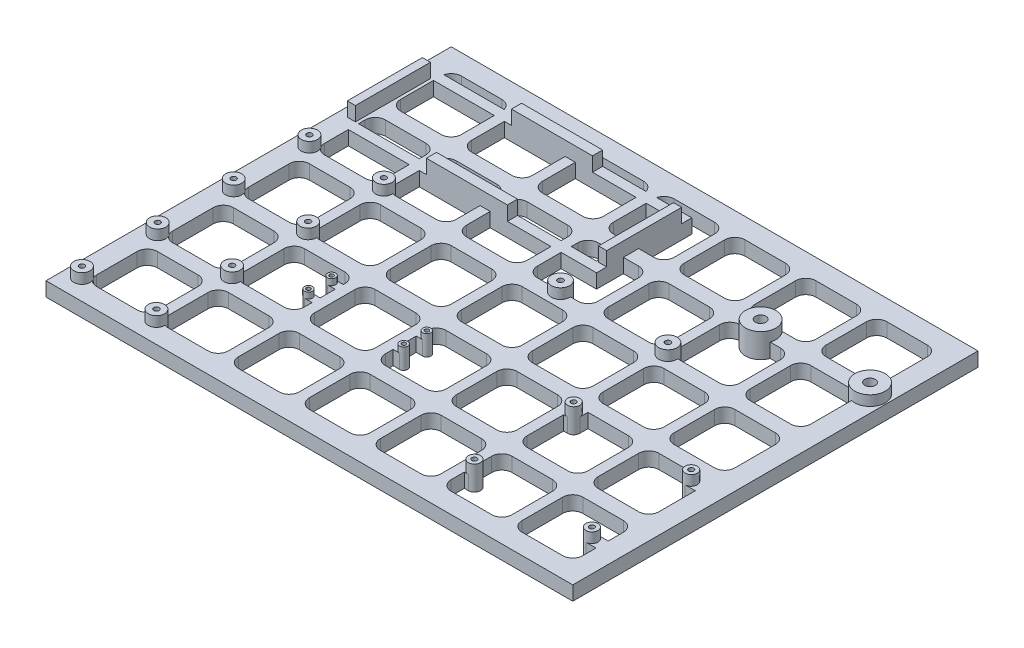
from build123d import *

# Parameters (mm, degrees)
SKETCH1_W                  = 260
SKETCH1_H                  = 200
BOSS_EXTRUDE1_DEPTH        = 7
CUT_EXTRUDE4_DEPTH         = 10
SKETCH10_R                 = 7.5
BOSS_EXTRUDE3_DEPTH        = 5
BOSS_EXTRUDE3_DEPTH_BACK   = 7
SKETCH11_R                 = 2.6
CUT_EXTRUDE2_DEPTH         = 13
SKETCH16_R                 = 4
BOSS_EXTRUDE6_DEPTH        = 5
BOSS_EXTRUDE6_DEPTH_BACK   = 7
SKETCH17_R                 = 1.3
CUT_EXTRUDE5_DEPTH         = 13
SKETCH18_R                 = 4.5
BOSS_EXTRUDE7_DEPTH        = 5
BOSS_EXTRUDE7_DEPTH_BACK   = 7
SKETCH19_R                 = 1.35
CUT_EXTRUDE6_DEPTH         = 13
SKETCH9_R                  = 6
BOSS_EXTRUDE2_DEPTH        = 5
BOSS_EXTRUDE2_DEPTH_BACK   = 7
SKETCH8_R                  = 1.25
CUT_EXTRUDE1_DEPTH         = 6
CUT_EXTRUDE1_DEPTH_BACK    = 8
SKETCH28_R                 = 7
SKETCH28_R_2               = 3
CUT_EXTRUDE8_DEPTH         = 5
SKETCH20_W                 = 4
SKETCH20_H                 = 37
SKETCH20_W_2               = 40
SKETCH20_H_2               = 5
BOSS_EXTRUDE8_DEPTH        = 7
SKETCH26_W                 = 128
SKETCH26_H                 = 47
SKETCH26_W_2               = 118
SKETCH26_H_2               = 37
BOSS_EXTRUDE12_DEPTH       = 7
SKETCH23_R                 = 2
BOSS_EXTRUDE9_DEPTH        = 3
BOSS_EXTRUDE9_DEPTH_BACK   = 7
BOSS_EXTRUDE9_2_DEPTH      = 3
BOSS_EXTRUDE9_2_DEPTH_BACK = 7
BOSS_EXTRUDE9_3_DEPTH      = 3
BOSS_EXTRUDE9_3_DEPTH_BACK = 7
BOSS_EXTRUDE9_4_DEPTH      = 3
BOSS_EXTRUDE9_4_DEPTH_BACK = 7
CUT_EXTRUDE10_DEPTH        = 8
BOSS_EXTRUDE13_DEPTH       = 7
SKETCH24_R                 = 1
CUT_EXTRUDE12_DEPTH        = 5
CUT_EXTRUDE12_DEPTH_BACK   = 11


with BuildPart() as part:
    # Sketch1 → Boss-Extrude1 (new body)
    with BuildSketch(Plane(origin=(0, 0, 0), x_dir=(1, 0, 0), z_dir=(0, 1, 0))):
        Rectangle(SKETCH1_W, SKETCH1_H)
    extrude(amount=BOSS_EXTRUDE1_DEPTH)

    # Sketch15 → Cut-Extrude4 (cut)
    with BuildSketch(Plane(origin=(0, 7, 0), x_dir=(1, 0, 0), z_dir=(0, 1, 0))):
        with BuildLine():
            Line((-115, 90), (-95, 90))
            ThreePointArc((-95, 90), (-91.464466094, 88.535533906), (-90, 85))
            Line((-90, 85), (-90, 65))
            ThreePointArc((-90, 65), (-91.464466094, 61.464466094), (-95, 60))
            Line((-95, 60), (-115, 60))
            ThreePointArc((-115, 60), (-118.535533906, 61.464466094), (-120, 65))
            Line((-120, 65), (-120, 85))
            ThreePointArc((-120, 85), (-118.535533906, 88.535533906), (-115, 90))
        make_face()
        with BuildLine():
            Line((-85, 85), (-85, 65))
            ThreePointArc((-85, 65), (-83.535533906, 61.464466094), (-80, 60))
            Line((-80, 60), (-60, 60))
            ThreePointArc((-60, 60), (-56.464466094, 61.464466094), (-55, 65))
            Line((-55, 65), (-55, 85))
            ThreePointArc((-55, 85), (-56.464466094, 88.535533906), (-60, 90))
            Line((-60, 90), (-80, 90))
            ThreePointArc((-80, 90), (-83.535533906, 88.535533906), (-85, 85))
        make_face()
        with BuildLine():
            Line((-50, 85), (-50, 65))
            ThreePointArc((-50, 65), (-48.535533906, 61.464466094), (-45, 60))
            Line((-45, 60), (-25, 60))
            ThreePointArc((-25, 60), (-21.464466094, 61.464466094), (-20, 65))
            Line((-20, 65), (-20, 85))
            ThreePointArc((-20, 85), (-21.464466094, 88.535533906), (-25, 90))
            Line((-25, 90), (-45, 90))
            ThreePointArc((-45, 90), (-48.535533906, 88.535533906), (-50, 85))
        make_face()
        with BuildLine():
            Line((-15, 85), (-15, 65))
            ThreePointArc((-15, 65), (-13.535533906, 61.464466094), (-10, 60))
            Line((-10, 60), (10, 60))
            ThreePointArc((10, 60), (13.535533906, 61.464466094), (15, 65))
            Line((15, 65), (15, 85))
            ThreePointArc((15, 85), (13.535533906, 88.535533906), (10, 90))
            Line((10, 90), (-10, 90))
            ThreePointArc((-10, 90), (-13.535533906, 88.535533906), (-15, 85))
        make_face()
        with BuildLine():
            Line((20, 85), (20, 65))
            ThreePointArc((20, 65), (21.464466094, 61.464466094), (25, 60))
            Line((25, 60), (45, 60))
            ThreePointArc((45, 60), (48.535533906, 61.464466094), (50, 65))
            Line((50, 65), (50, 85))
            ThreePointArc((50, 85), (48.535533906, 88.535533906), (45, 90))
            Line((45, 90), (25, 90))
            ThreePointArc((25, 90), (21.464466094, 88.535533906), (20, 85))
        make_face()
        with BuildLine():
            Line((55, 85), (55, 65))
            ThreePointArc((55, 65), (56.464466094, 61.464466094), (60, 60))
            Line((60, 60), (80, 60))
            ThreePointArc((80, 60), (83.535533906, 61.464466094), (85, 65))
            Line((85, 65), (85, 85))
            ThreePointArc((85, 85), (83.535533906, 88.535533906), (80, 90))
            Line((80, 90), (60, 90))
            ThreePointArc((60, 90), (56.464466094, 88.535533906), (55, 85))
        make_face()
        with BuildLine():
            Line((90, 85), (90, 65))
            ThreePointArc((90, 65), (91.464466094, 61.464466094), (95, 60))
            Line((95, 60), (115, 60))
            ThreePointArc((115, 60), (118.535533906, 61.464466094), (120, 65))
            Line((120, 65), (120, 85))
            ThreePointArc((120, 85), (118.535533906, 88.535533906), (115, 90))
            Line((115, 90), (95, 90))
            ThreePointArc((95, 90), (91.464466094, 88.535533906), (90, 85))
        make_face()
        with BuildLine():
            Line((-85, 47.5), (-85, 27.5))
            ThreePointArc((-85, 27.5), (-83.535533906, 23.964466094), (-80, 22.5))
            Line((-80, 22.5), (-60, 22.5))
            ThreePointArc((-60, 22.5), (-56.464466094, 23.964466094), (-55, 27.5))
            Line((-55, 27.5), (-55, 47.5))
            ThreePointArc((-55, 47.5), (-56.464466094, 51.035533906), (-60, 52.5))
            Line((-60, 52.5), (-80, 52.5))
            ThreePointArc((-80, 52.5), (-83.535533906, 51.035533906), (-85, 47.5))
        make_face()
        with BuildLine():
            Line((-50, 47.5), (-50, 27.5))
            ThreePointArc((-50, 27.5), (-48.535533906, 23.964466094), (-45, 22.5))
            Line((-45, 22.5), (-25, 22.5))
            ThreePointArc((-25, 22.5), (-21.464466094, 23.964466094), (-20, 27.5))
            Line((-20, 27.5), (-20, 47.5))
            ThreePointArc((-20, 47.5), (-21.464466094, 51.035533906), (-25, 52.5))
            Line((-25, 52.5), (-45, 52.5))
            ThreePointArc((-45, 52.5), (-48.535533906, 51.035533906), (-50, 47.5))
        make_face()
        with BuildLine():
            Line((-15, 47.5), (-15, 27.5))
            ThreePointArc((-15, 27.5), (-13.535533906, 23.964466094), (-10, 22.5))
            Line((-10, 22.5), (10, 22.5))
            ThreePointArc((10, 22.5), (13.535533906, 23.964466094), (15, 27.5))
            Line((15, 27.5), (15, 47.5))
            ThreePointArc((15, 47.5), (13.535533906, 51.035533906), (10, 52.5))
            Line((10, 52.5), (-10, 52.5))
            ThreePointArc((-10, 52.5), (-13.535533906, 51.035533906), (-15, 47.5))
        make_face()
        with BuildLine():
            Line((20, 47.5), (20, 27.5))
            ThreePointArc((20, 27.5), (21.464466094, 23.964466094), (25, 22.5))
            Line((25, 22.5), (45, 22.5))
            ThreePointArc((45, 22.5), (48.535533906, 23.964466094), (50, 27.5))
            Line((50, 27.5), (50, 47.5))
            ThreePointArc((50, 47.5), (48.535533906, 51.035533906), (45, 52.5))
            Line((45, 52.5), (25, 52.5))
            ThreePointArc((25, 52.5), (21.464466094, 51.035533906), (20, 47.5))
        make_face()
        with BuildLine():
            Line((55, 47.5), (55, 27.5))
            ThreePointArc((55, 27.5), (56.464466094, 23.964466094), (60, 22.5))
            Line((60, 22.5), (80, 22.5))
            ThreePointArc((80, 22.5), (83.535533906, 23.964466094), (85, 27.5))
            Line((85, 27.5), (85, 47.5))
            ThreePointArc((85, 47.5), (83.535533906, 51.035533906), (80, 52.5))
            Line((80, 52.5), (60, 52.5))
            ThreePointArc((60, 52.5), (56.464466094, 51.035533906), (55, 47.5))
        make_face()
        with BuildLine():
            Line((90, 47.5), (90, 27.5))
            ThreePointArc((90, 27.5), (91.464466094, 23.964466094), (95, 22.5))
            Line((95, 22.5), (115, 22.5))
            ThreePointArc((115, 22.5), (118.535533906, 23.964466094), (120, 27.5))
            Line((120, 27.5), (120, 47.5))
            ThreePointArc((120, 47.5), (118.535533906, 51.035533906), (115, 52.5))
            Line((115, 52.5), (95, 52.5))
            ThreePointArc((95, 52.5), (91.464466094, 51.035533906), (90, 47.5))
        make_face()
        with BuildLine():
            Line((-85, 10), (-85, -10))
            ThreePointArc((-85, -10), (-83.535533906, -13.535533906), (-80, -15))
            Line((-80, -15), (-60, -15))
            ThreePointArc((-60, -15), (-56.464466094, -13.535533906), (-55, -10))
            Line((-55, -10), (-55, 10))
            ThreePointArc((-55, 10), (-56.464466094, 13.535533906), (-60, 15))
            Line((-60, 15), (-80, 15))
            ThreePointArc((-80, 15), (-83.535533906, 13.535533906), (-85, 10))
        make_face()
        with BuildLine():
            Line((-50, 10), (-50, -10))
            ThreePointArc((-50, -10), (-48.535533906, -13.535533906), (-45, -15))
            Line((-45, -15), (-25, -15))
            ThreePointArc((-25, -15), (-21.464466094, -13.535533906), (-20, -10))
            Line((-20, -10), (-20, 10))
            ThreePointArc((-20, 10), (-21.464466094, 13.535533906), (-25, 15))
            Line((-25, 15), (-45, 15))
            ThreePointArc((-45, 15), (-48.535533906, 13.535533906), (-50, 10))
        make_face()
        with BuildLine():
            Line((-15, 10), (-15, -10))
            ThreePointArc((-15, -10), (-13.535533906, -13.535533906), (-10, -15))
            Line((-10, -15), (10, -15))
            ThreePointArc((10, -15), (13.535533906, -13.535533906), (15, -10))
            Line((15, -10), (15, 10))
            ThreePointArc((15, 10), (13.535533906, 13.535533906), (10, 15))
            Line((10, 15), (-10, 15))
            ThreePointArc((-10, 15), (-13.535533906, 13.535533906), (-15, 10))
        make_face()
        with BuildLine():
            Line((20, 10), (20, -10))
            ThreePointArc((20, -10), (21.464466094, -13.535533906), (25, -15))
            Line((25, -15), (45, -15))
            ThreePointArc((45, -15), (48.535533906, -13.535533906), (50, -10))
            Line((50, -10), (50, 10))
            ThreePointArc((50, 10), (48.535533906, 13.535533906), (45, 15))
            Line((45, 15), (25, 15))
            ThreePointArc((25, 15), (21.464466094, 13.535533906), (20, 10))
        make_face()
        with BuildLine():
            Line((55, 10), (55, -10))
            ThreePointArc((55, -10), (56.464466094, -13.535533906), (60, -15))
            Line((60, -15), (80, -15))
            ThreePointArc((80, -15), (83.535533906, -13.535533906), (85, -10))
            Line((85, -10), (85, 10))
            ThreePointArc((85, 10), (83.535533906, 13.535533906), (80, 15))
            Line((80, 15), (60, 15))
            ThreePointArc((60, 15), (56.464466094, 13.535533906), (55, 10))
        make_face()
        with BuildLine():
            Line((90, 10), (90, -10))
            ThreePointArc((90, -10), (91.464466094, -13.535533906), (95, -15))
            Line((95, -15), (115, -15))
            ThreePointArc((115, -15), (118.535533906, -13.535533906), (120, -10))
            Line((120, -10), (120, 10))
            ThreePointArc((120, 10), (118.535533906, 13.535533906), (115, 15))
            Line((115, 15), (95, 15))
            ThreePointArc((95, 15), (91.464466094, 13.535533906), (90, 10))
        make_face()
        with BuildLine():
            Line((-85, -27.5), (-85, -47.5))
            ThreePointArc((-85, -47.5), (-83.535533906, -51.035533906), (-80, -52.5))
            Line((-80, -52.5), (-60, -52.5))
            ThreePointArc((-60, -52.5), (-56.464466094, -51.035533906), (-55, -47.5))
            Line((-55, -47.5), (-55, -27.5))
            ThreePointArc((-55, -27.5), (-56.464466094, -23.964466094), (-60, -22.5))
            Line((-60, -22.5), (-80, -22.5))
            ThreePointArc((-80, -22.5), (-83.535533906, -23.964466094), (-85, -27.5))
        make_face()
        with BuildLine():
            Line((-50, -27.5), (-50, -47.5))
            ThreePointArc((-50, -47.5), (-48.535533906, -51.035533906), (-45, -52.5))
            Line((-45, -52.5), (-25, -52.5))
            ThreePointArc((-25, -52.5), (-21.464466094, -51.035533906), (-20, -47.5))
            Line((-20, -47.5), (-20, -27.5))
            ThreePointArc((-20, -27.5), (-21.464466094, -23.964466094), (-25, -22.5))
            Line((-25, -22.5), (-45, -22.5))
            ThreePointArc((-45, -22.5), (-48.535533906, -23.964466094), (-50, -27.5))
        make_face()
        with BuildLine():
            Line((-15, -27.5), (-15, -47.5))
            ThreePointArc((-15, -47.5), (-13.535533906, -51.035533906), (-10, -52.5))
            Line((-10, -52.5), (10, -52.5))
            ThreePointArc((10, -52.5), (13.535533906, -51.035533906), (15, -47.5))
            Line((15, -47.5), (15, -27.5))
            ThreePointArc((15, -27.5), (13.535533906, -23.964466094), (10, -22.5))
            Line((10, -22.5), (-10, -22.5))
            ThreePointArc((-10, -22.5), (-13.535533906, -23.964466094), (-15, -27.5))
        make_face()
        with BuildLine():
            Line((20, -27.5), (20, -47.5))
            ThreePointArc((20, -47.5), (21.464466094, -51.035533906), (25, -52.5))
            Line((25, -52.5), (45, -52.5))
            ThreePointArc((45, -52.5), (48.535533906, -51.035533906), (50, -47.5))
            Line((50, -47.5), (50, -27.5))
            ThreePointArc((50, -27.5), (48.535533906, -23.964466094), (45, -22.5))
            Line((45, -22.5), (25, -22.5))
            ThreePointArc((25, -22.5), (21.464466094, -23.964466094), (20, -27.5))
        make_face()
        with BuildLine():
            Line((55, -27.5), (55, -47.5))
            ThreePointArc((55, -47.5), (56.464466094, -51.035533906), (60, -52.5))
            Line((60, -52.5), (80, -52.5))
            ThreePointArc((80, -52.5), (83.535533906, -51.035533906), (85, -47.5))
            Line((85, -47.5), (85, -27.5))
            ThreePointArc((85, -27.5), (83.535533906, -23.964466094), (80, -22.5))
            Line((80, -22.5), (60, -22.5))
            ThreePointArc((60, -22.5), (56.464466094, -23.964466094), (55, -27.5))
        make_face()
        with BuildLine():
            Line((90, -27.5), (90, -47.5))
            ThreePointArc((90, -47.5), (91.464466094, -51.035533906), (95, -52.5))
            Line((95, -52.5), (115, -52.5))
            ThreePointArc((115, -52.5), (118.535533906, -51.035533906), (120, -47.5))
            Line((120, -47.5), (120, -27.5))
            ThreePointArc((120, -27.5), (118.535533906, -23.964466094), (115, -22.5))
            Line((115, -22.5), (95, -22.5))
            ThreePointArc((95, -22.5), (91.464466094, -23.964466094), (90, -27.5))
        make_face()
        with BuildLine():
            Line((-85, -65), (-85, -85))
            ThreePointArc((-85, -85), (-83.535533906, -88.535533906), (-80, -90))
            Line((-80, -90), (-60, -90))
            ThreePointArc((-60, -90), (-56.464466094, -88.535533906), (-55, -85))
            Line((-55, -85), (-55, -65))
            ThreePointArc((-55, -65), (-56.464466094, -61.464466094), (-60, -60))
            Line((-60, -60), (-80, -60))
            ThreePointArc((-80, -60), (-83.535533906, -61.464466094), (-85, -65))
        make_face()
        with BuildLine():
            Line((-50, -65), (-50, -85))
            ThreePointArc((-50, -85), (-48.535533906, -88.535533906), (-45, -90))
            Line((-45, -90), (-25, -90))
            ThreePointArc((-25, -90), (-21.464466094, -88.535533906), (-20, -85))
            Line((-20, -85), (-20, -65))
            ThreePointArc((-20, -65), (-21.464466094, -61.464466094), (-25, -60))
            Line((-25, -60), (-45, -60))
            ThreePointArc((-45, -60), (-48.535533906, -61.464466094), (-50, -65))
        make_face()
        with BuildLine():
            Line((-15, -65), (-15, -85))
            ThreePointArc((-15, -85), (-13.535533906, -88.535533906), (-10, -90))
            Line((-10, -90), (10, -90))
            ThreePointArc((10, -90), (13.535533906, -88.535533906), (15, -85))
            Line((15, -85), (15, -65))
            ThreePointArc((15, -65), (13.535533906, -61.464466094), (10, -60))
            Line((10, -60), (-10, -60))
            ThreePointArc((-10, -60), (-13.535533906, -61.464466094), (-15, -65))
        make_face()
        with BuildLine():
            Line((20, -65), (20, -85))
            ThreePointArc((20, -85), (21.464466094, -88.535533906), (25, -90))
            Line((25, -90), (45, -90))
            ThreePointArc((45, -90), (48.535533906, -88.535533906), (50, -85))
            Line((50, -85), (50, -65))
            ThreePointArc((50, -65), (48.535533906, -61.464466094), (45, -60))
            Line((45, -60), (25, -60))
            ThreePointArc((25, -60), (21.464466094, -61.464466094), (20, -65))
        make_face()
        with BuildLine():
            Line((55, -65), (55, -85))
            ThreePointArc((55, -85), (56.464466094, -88.535533906), (60, -90))
            Line((60, -90), (80, -90))
            ThreePointArc((80, -90), (83.535533906, -88.535533906), (85, -85))
            Line((85, -85), (85, -65))
            ThreePointArc((85, -65), (83.535533906, -61.464466094), (80, -60))
            Line((80, -60), (60, -60))
            ThreePointArc((60, -60), (56.464466094, -61.464466094), (55, -65))
        make_face()
        with BuildLine():
            Line((90, -65), (90, -85))
            ThreePointArc((90, -85), (91.464466094, -88.535533906), (95, -90))
            Line((95, -90), (115, -90))
            ThreePointArc((115, -90), (118.535533906, -88.535533906), (120, -85))
            Line((120, -85), (120, -65))
            ThreePointArc((120, -65), (118.535533906, -61.464466094), (115, -60))
            Line((115, -60), (95, -60))
            ThreePointArc((95, -60), (91.464466094, -61.464466094), (90, -65))
        make_face()
        with BuildLine():
            Line((-120, 47.5), (-120, 27.5))
            ThreePointArc((-120, 27.5), (-118.535533906, 23.964466094), (-115, 22.5))
            Line((-115, 22.5), (-95, 22.5))
            ThreePointArc((-95, 22.5), (-91.464466094, 23.964466094), (-90, 27.5))
            Line((-90, 27.5), (-90, 47.5))
            ThreePointArc((-90, 47.5), (-91.464466094, 51.035533906), (-95, 52.5))
            Line((-95, 52.5), (-115, 52.5))
            ThreePointArc((-115, 52.5), (-118.535533906, 51.035533906), (-120, 47.5))
        make_face()
        with BuildLine():
            Line((-120, 10), (-120, -10))
            ThreePointArc((-120, -10), (-118.535533906, -13.535533906), (-115, -15))
            Line((-115, -15), (-95, -15))
            ThreePointArc((-95, -15), (-91.464466094, -13.535533906), (-90, -10))
            Line((-90, -10), (-90, 10))
            ThreePointArc((-90, 10), (-91.464466094, 13.535533906), (-95, 15))
            Line((-95, 15), (-115, 15))
            ThreePointArc((-115, 15), (-118.535533906, 13.535533906), (-120, 10))
        make_face()
        with BuildLine():
            Line((-120, -27.5), (-120, -47.5))
            ThreePointArc((-120, -47.5), (-118.535533906, -51.035533906), (-115, -52.5))
            Line((-115, -52.5), (-95, -52.5))
            ThreePointArc((-95, -52.5), (-91.464466094, -51.035533906), (-90, -47.5))
            Line((-90, -47.5), (-90, -27.5))
            ThreePointArc((-90, -27.5), (-91.464466094, -23.964466094), (-95, -22.5))
            Line((-95, -22.5), (-115, -22.5))
            ThreePointArc((-115, -22.5), (-118.535533906, -23.964466094), (-120, -27.5))
        make_face()
        with BuildLine():
            Line((-120, -65), (-120, -85))
            ThreePointArc((-120, -85), (-118.535533906, -88.535533906), (-115, -90))
            Line((-115, -90), (-95, -90))
            ThreePointArc((-95, -90), (-91.464466094, -88.535533906), (-90, -85))
            Line((-90, -85), (-90, -65))
            ThreePointArc((-90, -65), (-91.464466094, -61.464466094), (-95, -60))
            Line((-95, -60), (-115, -60))
            ThreePointArc((-115, -60), (-118.535533906, -61.464466094), (-120, -65))
        make_face()
    extrude(amount=-CUT_EXTRUDE4_DEPTH, mode=Mode.SUBTRACT)

    # Sketch10 → Boss-Extrude3 (add, two sides)
    with BuildSketch(Plane(origin=(0, 7, 0), x_dir=(1, 0, 0), z_dir=(0, 1, 0))) as boss_extrude3_sk:
        with Locations((67.819740349, 54.898416851)):
            Circle(SKETCH10_R)
        with Locations((121.819740349, 54.898416851)):
            Circle(SKETCH10_R)
    extrude(amount=BOSS_EXTRUDE3_DEPTH)
    extrude(boss_extrude3_sk.sketch, amount=-BOSS_EXTRUDE3_DEPTH_BACK)

    # Sketch11 → Cut-Extrude2 (cut, through all)
    with BuildSketch(Plane(origin=(0, 12, 0), x_dir=(1, 0, 0), z_dir=(0, 1, 0))):
        with Locations((67.819740349, 54.898416851)):
            Circle(SKETCH11_R)
        with Locations((121.819740349, 54.898416851)):
            Circle(SKETCH11_R)
    extrude(amount=-CUT_EXTRUDE2_DEPTH, mode=Mode.SUBTRACT)

    # Sketch16 → Boss-Extrude6 (add, two sides)
    with BuildSketch(Plane(origin=(0, 7, 0), x_dir=(1, 0, 0), z_dir=(0, 1, 0))) as boss_extrude6_sk:
        with Locations((-122.3709, -89.881222269)):
            Circle(SKETCH16_R)
        with Locations((-85.6291, -89.881222269)):
            Circle(SKETCH16_R)
        with Locations((-85.6291, -52.501722269)):
            Circle(SKETCH16_R)
        with Locations((-122.3709, -52.501722269)):
            Circle(SKETCH16_R)
        with Locations((-122.3709, -14.984574719)):
            Circle(SKETCH16_R)
        with Locations((-85.6291, -14.984574719)):
            Circle(SKETCH16_R)
        with Locations((-85.6291, 22.394925281)):
            Circle(SKETCH16_R)
        with Locations((-122.3709, 22.394925281)):
            Circle(SKETCH16_R)
    extrude(amount=BOSS_EXTRUDE6_DEPTH)
    extrude(boss_extrude6_sk.sketch, amount=-BOSS_EXTRUDE6_DEPTH_BACK)

    # Sketch17 → Cut-Extrude5 (cut, through all)
    with BuildSketch(Plane(origin=(0, 12, 0), x_dir=(1, 0, 0), z_dir=(0, 1, 0))):
        with Locations((-122.3709, -52.501722269)):
            Circle(SKETCH17_R)
        with Locations((-85.6291, -52.501722269)):
            Circle(SKETCH17_R)
        with Locations((-85.6291, -89.881222269)):
            Circle(SKETCH17_R)
        with Locations((-122.3709, -89.881222269)):
            Circle(SKETCH17_R)
        with Locations((-122.3709, -14.984574719)):
            Circle(SKETCH17_R)
        with Locations((-122.3709, 22.394925281)):
            Circle(SKETCH17_R)
        with Locations((-85.6291, 22.394925281)):
            Circle(SKETCH17_R)
        with Locations((-85.6291, -14.984574719)):
            Circle(SKETCH17_R)
    extrude(amount=-CUT_EXTRUDE5_DEPTH, mode=Mode.SUBTRACT)

    # Sketch18 → Boss-Extrude7 (add, two sides)
    with BuildSketch(Plane(origin=(0, 7, 0), x_dir=(1, 0, 0), z_dir=(0, 1, 0))) as boss_extrude7_sk:
        with Locations((1.833333333, 22.121784759)):
            Circle(SKETCH18_R)
        with Locations((54.833333333, 22.121784759)):
            Circle(SKETCH18_R)
    extrude(amount=BOSS_EXTRUDE7_DEPTH)
    extrude(boss_extrude7_sk.sketch, amount=-BOSS_EXTRUDE7_DEPTH_BACK)

    # Sketch19 → Cut-Extrude6 (cut, through all)
    with BuildSketch(Plane(origin=(0, 12, 0), x_dir=(1, 0, 0), z_dir=(0, 1, 0))):
        with Locations((1.833333333, 22.121784759)):
            Circle(SKETCH19_R)
        with Locations((54.833333333, 22.121784759)):
            Circle(SKETCH19_R)
    extrude(amount=-CUT_EXTRUDE6_DEPTH, mode=Mode.SUBTRACT)

    # Sketch9 → Boss-Extrude2 (add, two sides)
    with BuildSketch(Plane(origin=(0, 7, 0), x_dir=(1, 0, 0), z_dir=(0, 1, 0))) as boss_extrude2_sk:
        with Locations((56.97501713, -26.535533906)):
            Circle(SKETCH9_R)
        with Locations((114.97501713, -26.535533906)):
            Circle(SKETCH9_R)
        with Locations((114.97501713, -75.535533906)):
            Circle(SKETCH9_R)
        with Locations((56.97501713, -75.535533906)):
            Circle(SKETCH9_R)
    extrude(amount=BOSS_EXTRUDE2_DEPTH)
    extrude(boss_extrude2_sk.sketch, amount=-BOSS_EXTRUDE2_DEPTH_BACK)

    # Sketch8 → Cut-Extrude1 (cut, two sides)
    with BuildSketch(Plane(origin=(0, 7, 0), x_dir=(1, 0, 0), z_dir=(0, 1, 0))) as cut_extrude1_sk:
        with Locations((114.97501713, -75.535533906)):
            Circle(SKETCH8_R)
        with Locations((56.97501713, -75.535533906)):
            Circle(SKETCH8_R)
        with Locations((56.97501713, -26.535533906)):
            Circle(SKETCH8_R)
        with Locations((114.97501713, -26.535533906)):
            Circle(SKETCH8_R)
    extrude(amount=CUT_EXTRUDE1_DEPTH, mode=Mode.SUBTRACT)
    extrude(cut_extrude1_sk.sketch, amount=-CUT_EXTRUDE1_DEPTH_BACK, mode=Mode.SUBTRACT)

    # Sketch28 → Cut-Extrude8 (cut)
    with BuildSketch(Plane(origin=(0, 12, 0), x_dir=(1, 0, 0), z_dir=(0, 1, 0))):
        with Locations((56.97501713, -75.535533906)):
            Circle(SKETCH28_R)
        with Locations((56.97501713, -75.535533906)):
            Circle(SKETCH28_R_2, mode=Mode.SUBTRACT)
        with Locations((114.97501713, -75.535533906)):
            Circle(SKETCH28_R)
        with Locations((114.97501713, -75.535533906)):
            Circle(SKETCH28_R_2, mode=Mode.SUBTRACT)
        with Locations((56.97501713, -26.535533906)):
            Circle(SKETCH28_R)
        with Locations((56.97501713, -26.535533906)):
            Circle(SKETCH28_R_2, mode=Mode.SUBTRACT)
        with Locations((114.97501713, -26.535533906)):
            Circle(SKETCH28_R)
        with Locations((114.97501713, -26.535533906)):
            Circle(SKETCH28_R_2, mode=Mode.SUBTRACT)
    extrude(amount=-CUT_EXTRUDE8_DEPTH, mode=Mode.SUBTRACT)

    # Sketch20 → Boss-Extrude8 (add)
    with BuildSketch(Plane(origin=(0, 7, 0), x_dir=(1, 0, 0), z_dir=(0, 1, 0))):
        with Locations((-123.513851374, 62.741803697)):
            Rectangle(SKETCH20_W, SKETCH20_H)
        with Locations((0.486148626, 62.741803697)):
            Rectangle(SKETCH20_W, SKETCH20_H)
        with Locations((-61.513851374, 83.741803697)):
            Rectangle(SKETCH20_W_2, SKETCH20_H_2)
        with Locations((-61.513851374, 41.741803697)):
            Rectangle(SKETCH20_W_2, SKETCH20_H_2)
    extrude(amount=BOSS_EXTRUDE8_DEPTH)

    # Sketch26 → Boss-Extrude12 (add)
    with BuildSketch(Plane(origin=(0, 7, 0), x_dir=(1, 0, 0), z_dir=(0, 1, 0))):
        with Locations((-61.513851374, 62.741803697)):
            Rectangle(SKETCH26_W, SKETCH26_H)
        with Locations((-61.513851374, 62.741803697)):
            Rectangle(SKETCH26_W_2, SKETCH26_H_2, mode=Mode.SUBTRACT)
    extrude(amount=-BOSS_EXTRUDE12_DEPTH)

    # Sketch30 → Cut-Extrude10 (cut, through all)
    with BuildSketch(Plane(origin=(0, 7, 0), x_dir=(1, 0, 0), z_dir=(0, 1, 0))):
        with BuildLine():
            Line((55, -69.869908845), (55, -72.535533906))
            Line((55, -72.535533906), (56.97501713, -72.535533906))
            ThreePointArc((56.97501713, -72.535533906), (59.096337474, -73.414213562), (59.97501713, -75.535533906))
            ThreePointArc((59.97501713, -75.535533906), (59.096337474, -77.656854249), (56.97501713, -78.535533906))
            Line((56.97501713, -78.535533906), (55, -78.535533906))
            Line((55, -78.535533906), (55, -81.201158967))
            ThreePointArc((55, -81.201158967), (62.97501713, -75.535533906), (55, -69.869908845))
        make_face()
        with BuildLine():
            Line((120, -72.256883702), (120, -72.535533906))
            Line((120, -72.535533906), (114.97501713, -72.535533906))
            ThreePointArc((114.97501713, -72.535533906), (111.97501713, -75.535533906), (114.97501713, -78.535533906))
            Line((114.97501713, -78.535533906), (120, -78.535533906))
            Line((120, -78.535533906), (120, -78.81418411))
            ThreePointArc((120, -78.81418411), (108.97501713, -75.535533906), (120, -72.256883702))
        make_face()
        with BuildLine():
            Line((114.97501713, -29.535533906), (120, -29.535533906))
            Line((120, -29.535533906), (120, -29.81418411))
            ThreePointArc((120, -29.81418411), (111.306250987, -31.283181217), (110.534919598, -22.5))
            Line((110.534919598, -22.5), (111.97501713, -22.5))
            Line((111.97501713, -22.5), (111.97501713, -26.535533906))
            ThreePointArc((111.97501713, -26.535533906), (112.853696787, -28.656854249), (114.97501713, -29.535533906))
        make_face()
        with BuildLine():
            Line((56.97501713, -29.535533906), (55, -29.535533906))
            Line((55, -29.535533906), (55, -32.201158967))
            ThreePointArc((55, -32.201158967), (61.979742565, -29.845023795), (61.415114662, -22.5))
            Line((61.415114662, -22.5), (59.97501713, -22.5))
            Line((59.97501713, -22.5), (59.97501713, -26.535533906))
            ThreePointArc((59.97501713, -26.535533906), (59.096337474, -28.656854249), (56.97501713, -29.535533906))
        make_face()
    extrude(amount=-CUT_EXTRUDE10_DEPTH, mode=Mode.SUBTRACT)



with BuildPart() as body_2:
    # Sketch23 → Boss-Extrude9 (new body, two sides)
    with BuildSketch(Plane(origin=(0, 7, 0), x_dir=(1, 0, 0), z_dir=(0, 1, 0))) as boss_extrude9_sk:
        with Locations((-58.783450413, -30.269655173)):
            Circle(SKETCH23_R)
    extrude(amount=BOSS_EXTRUDE9_DEPTH)
    extrude(boss_extrude9_sk.sketch, amount=-BOSS_EXTRUDE9_DEPTH_BACK)


with BuildPart() as body_3:
    # Sketch23 → Boss-Extrude9 2 (new body, two sides)
    with BuildSketch(Plane(origin=(0, 7, 0), x_dir=(1, 0, 0), z_dir=(0, 1, 0))) as boss_extrude9_2_sk:
        with Locations((-58.783450413, -41.669655173)):
            Circle(SKETCH23_R)
    extrude(amount=BOSS_EXTRUDE9_2_DEPTH)
    extrude(boss_extrude9_2_sk.sketch, amount=-BOSS_EXTRUDE9_2_DEPTH_BACK)


with BuildPart() as body_4:
    # Sketch23 → Boss-Extrude9 3 (new body, two sides)
    with BuildSketch(Plane(origin=(0, 7, 0), x_dir=(1, 0, 0), z_dir=(0, 1, 0))) as boss_extrude9_3_sk:
        with Locations((-11.783450413, -41.669655173)):
            Circle(SKETCH23_R)
    extrude(amount=BOSS_EXTRUDE9_3_DEPTH)
    extrude(boss_extrude9_3_sk.sketch, amount=-BOSS_EXTRUDE9_3_DEPTH_BACK)


with BuildPart() as body_5:
    # Sketch23 → Boss-Extrude9 4 (new body, two sides)
    with BuildSketch(Plane(origin=(0, 7, 0), x_dir=(1, 0, 0), z_dir=(0, 1, 0))) as boss_extrude9_4_sk:
        with Locations((-11.783450413, -30.269655173)):
            Circle(SKETCH23_R)
    extrude(amount=BOSS_EXTRUDE9_4_DEPTH)
    extrude(boss_extrude9_4_sk.sketch, amount=-BOSS_EXTRUDE9_4_DEPTH_BACK)


with BuildPart() as part_1:
    add(part.part)

    add(body_2.part)  # Boss-Extrude13 merges body 2

    add(body_3.part)  # Boss-Extrude13 merges body 3

    add(body_4.part)  # Boss-Extrude13 merges body 4

    add(body_5.part)  # Boss-Extrude13 merges body 5
    # Sketch31 → Boss-Extrude13 (add)
    with BuildSketch(Plane(origin=(0, 7, 0), x_dir=(1, 0, 0), z_dir=(0, 1, 0))):
        with BuildLine():
            Line((-58.783450413, -28.269655173), (-55, -28.269655173))
            Line((-55, -28.269655173), (-55, -32.269655173))
            Line((-55, -32.269655173), (-58.783450413, -32.269655173))
            ThreePointArc((-58.783450413, -32.269655173), (-60.783450413, -30.269655173), (-58.783450413, -28.269655173))
        make_face()
        with BuildLine():
            Line((-58.783450413, -39.669655173), (-55, -39.669655173))
            Line((-55, -39.669655173), (-55, -43.669655173))
            Line((-55, -43.669655173), (-58.783450413, -43.669655173))
            ThreePointArc((-58.783450413, -43.669655173), (-60.783450413, -41.669655173), (-58.783450413, -39.669655173))
        make_face()
        with BuildLine():
            Line((-11.783450413, -28.269655173), (-15, -28.269655173))
            Line((-15, -28.269655173), (-15, -32.269655173))
            Line((-15, -32.269655173), (-11.783450413, -32.269655173))
            ThreePointArc((-11.783450413, -32.269655173), (-9.783450413, -30.269655173), (-11.783450413, -28.269655173))
        make_face()
        with BuildLine():
            Line((-11.783450413, -39.669655173), (-15, -39.669655173))
            Line((-15, -39.669655173), (-15, -43.669655173))
            Line((-15, -43.669655173), (-11.783450413, -43.669655173))
            ThreePointArc((-11.783450413, -43.669655173), (-9.783450413, -41.669655173), (-11.783450413, -39.669655173))
        make_face()
    extrude(amount=-BOSS_EXTRUDE13_DEPTH)

    # Sketch24 → Cut-Extrude12 (cut, two sides)
    with BuildSketch(Plane(origin=(0, 10, 0), x_dir=(1, 0, 0), z_dir=(0, 1, 0))) as cut_extrude12_sk:
        with Locations((-58.783450413, -41.669655173)):
            Circle(SKETCH24_R)
        with Locations((-58.783450413, -30.269655173)):
            Circle(SKETCH24_R)
        with Locations((-11.783450413, -30.269655173)):
            Circle(SKETCH24_R)
        with Locations((-11.783450413, -41.669655173)):
            Circle(SKETCH24_R)
    extrude(amount=CUT_EXTRUDE12_DEPTH, mode=Mode.SUBTRACT)
    extrude(cut_extrude12_sk.sketch, amount=-CUT_EXTRUDE12_DEPTH_BACK, mode=Mode.SUBTRACT)


solid = part_1.part
